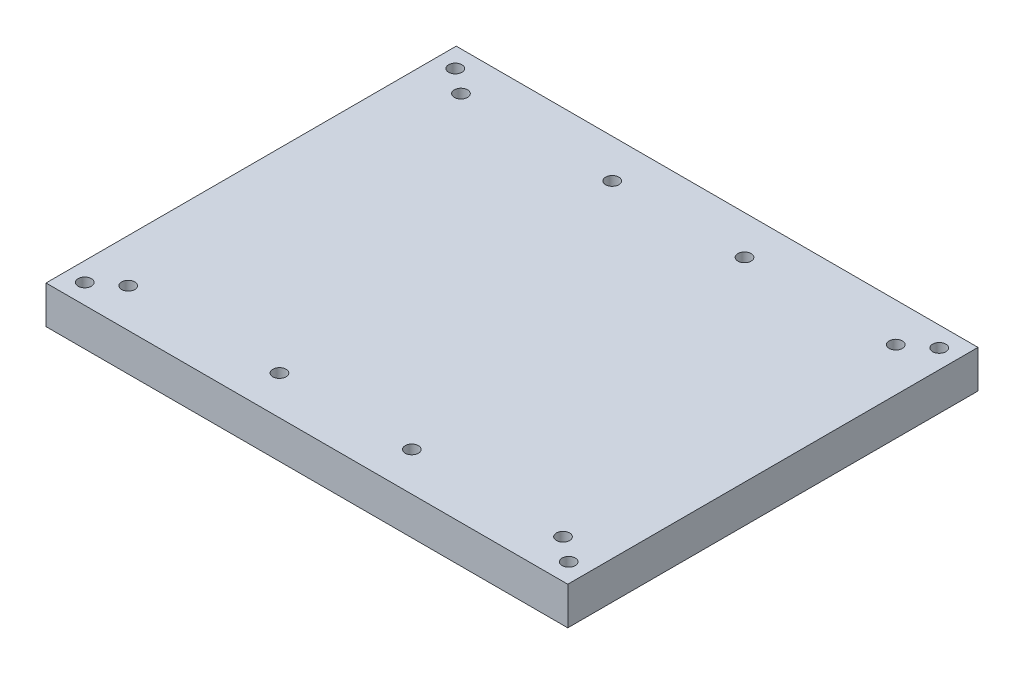
from build123d import *

# Parameters (mm, degrees)
SKETCH1_W           = 138
SKETCH1_H           = 108.5
SKETCH1_R           = 1.75
BOSS_EXTRUDE1_DEPTH = 10


with BuildPart() as part:
    # Sketch1 → Boss-Extrude1 (new body)
    with BuildSketch(Plane(origin=(0, 0, 0), x_dir=(1, 0, 0), z_dir=(0, 1, 0))):
        Rectangle(SKETCH1_W, SKETCH1_H)
        with Locations(Location((-64, 49, 0), (0, 0, 270))):  # turned: the seam where the file's is
            Circle(SKETCH1_R, mode=Mode.SUBTRACT)
        with Locations(Location((-64, -49, 0), (0, 0, 270))):  # turned: the seam where the file's is
            Circle(SKETCH1_R, mode=Mode.SUBTRACT)
        with Locations(Location((64, -49, 0), (0, 0, 270))):  # turned: the seam where the file's is
            Circle(SKETCH1_R, mode=Mode.SUBTRACT)
        with Locations(Location((64, 49, 0), (0, 0, 270))):  # turned: the seam where the file's is
            Circle(SKETCH1_R, mode=Mode.SUBTRACT)
        with Locations(Location((-57.5, 44, 0), (0, 0, 270))):  # turned: the seam where the file's is
            Circle(SKETCH1_R, mode=Mode.SUBTRACT)
        with Locations(Location((-17.5, 44, 0), (0, 0, 270))):  # turned: the seam where the file's is
            Circle(SKETCH1_R, mode=Mode.SUBTRACT)
        with Locations(Location((-17.5, -44, 0), (0, 0, 270))):  # turned: the seam where the file's is
            Circle(SKETCH1_R, mode=Mode.SUBTRACT)
        with Locations(Location((-57.5, -44, 0), (0, 0, 270))):  # turned: the seam where the file's is
            Circle(SKETCH1_R, mode=Mode.SUBTRACT)
        with Locations(Location((17.5, -44, 0), (0, 0, 270))):  # turned: the seam where the file's is
            Circle(SKETCH1_R, mode=Mode.SUBTRACT)
        with Locations(Location((57.5, -44, 0), (0, 0, 270))):  # turned: the seam where the file's is
            Circle(SKETCH1_R, mode=Mode.SUBTRACT)
        with Locations(Location((57.5, 44, 0), (0, 0, 270))):  # turned: the seam where the file's is
            Circle(SKETCH1_R, mode=Mode.SUBTRACT)
        with Locations(Location((17.5, 44, 0), (0, 0, 270))):  # turned: the seam where the file's is
            Circle(SKETCH1_R, mode=Mode.SUBTRACT)
    extrude(amount=BOSS_EXTRUDE1_DEPTH)


solid = part.part
